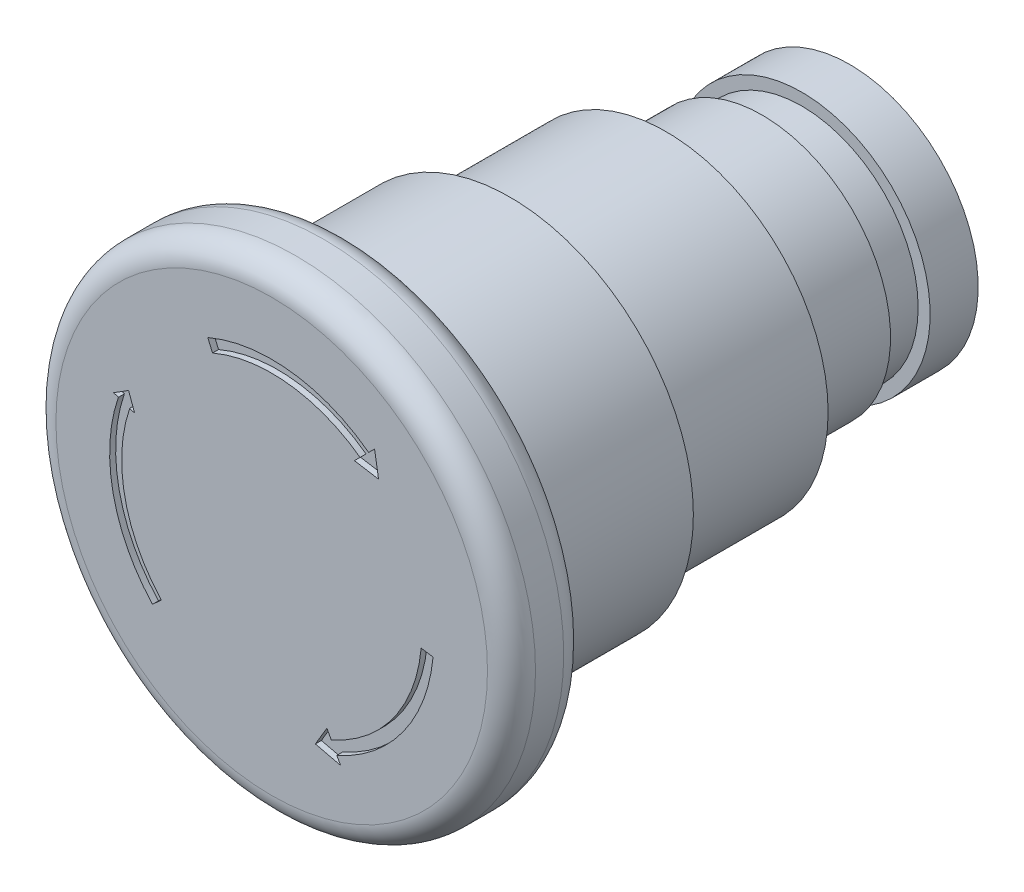
from build123d import *

# Parameters (mm, degrees)
SKETCH1_R           = 19.975
BOSS_EXTRUDE1_DEPTH = 6.35
SKETCH2_R           = 15.275
BOSS_EXTRUDE2_DEPTH = 13.5
SKETCH3_R           = 13.5
BOSS_EXTRUDE3_DEPTH = 13
SKETCH4_R           = 10.7
BOSS_EXTRUDE4_DEPTH = 15.3
FILLET1_R           = 2
SKETCH6_W           = 3.3
SKETCH6_H           = 1
CUT_EXTRUDE1_DEPTH  = 0.5


with BuildPart() as part:
    # Sketch1 → Boss-Extrude1 (new body)
    with BuildSketch(Plane.XY):
        Circle(SKETCH1_R)
    extrude(amount=BOSS_EXTRUDE1_DEPTH)

    # Sketch2 → Boss-Extrude2 (add)
    with BuildSketch(Plane(origin=(0, 0, 0), x_dir=(-1, 0, 0), z_dir=(0, 0, -1))):
        Circle(SKETCH2_R)
    extrude(amount=BOSS_EXTRUDE2_DEPTH)

    # Sketch3 → Boss-Extrude3 (add)
    with BuildSketch(Plane(origin=(0, 0, -13.5), x_dir=(-1, 0, 0), z_dir=(0, 0, -1))):
        Circle(SKETCH3_R)
    extrude(amount=BOSS_EXTRUDE3_DEPTH)

    # Sketch4 → Boss-Extrude4 (add)
    with BuildSketch(Plane(origin=(0, 0, -26.5), x_dir=(-1, 0, 0), z_dir=(0, 0, -1))):
        Circle(SKETCH4_R)
    extrude(amount=BOSS_EXTRUDE4_DEPTH)

    # Fillet1
    fillet1_edges = [part.edges().sort_by_distance(p)[0] for p in [
        (-19.975, 0, 0),
        (-19.975, 0, 6.35),
        (15.275, 0, 0),
    ]]
    fillet(fillet1_edges, radius=FILLET1_R)

    # Sketch6 → Cut-Revolve1 (revolve, cut)
    with BuildSketch(Plane(origin=(0, 0, 0), x_dir=(0, 0, -1), z_dir=(1, 0, 0))):
        with Locations((36.15, 10.2)):
            Rectangle(SKETCH6_W, SKETCH6_H)
    revolve(axis=Axis((0, 0, -41.8), (0, 0, 1)), mode=Mode.SUBTRACT)

    # Sketch7 → Cut-Extrude1 (cut)
    with BuildSketch(Plane.XY.offset(6.35)):
        with BuildLine():
            Line((7.361700557, 10.102245538), (6.889821654, 9.630366634))
            Line((6.889821654, 9.630366634), (8.901984725, 9.29752763))
            Line((8.901984725, 9.29752763), (8.569145721, 11.309690701))
            Line((8.569145721, 11.309690701), (8.076809244, 10.817354225))
            ThreePointArc((8.076809244, 10.817354225), (1.588975226, 13.406161186), (-5.32427617, 12.405727841))
            Line((-5.32427617, 12.405727841), (-4.929885342, 11.486785038))
            ThreePointArc((-4.929885342, 11.486785038), (1.399167151, 12.421446425), (7.361700557, 10.102245538))
        make_face()
        with BuildLine():
            Line((5.42803449, -12.360681275), (5.733177226, -12.931740939))
            Line((5.733177226, -12.931740939), (3.638222105, -12.432470591))
            Line((3.638222105, -12.432470591), (4.600377681, -10.81176215))
            Line((4.600377681, -10.81176215), (4.955240265, -11.475870072))
            ThreePointArc((4.955240265, -11.475870072), (10.129078424, -7.324736874), (12.450535159, -1.110933952))
            Line((12.450535159, -1.110933952), (13.440903952, -1.261784828))
            ThreePointArc((13.440903952, -1.261784828), (10.945573766, -7.90217786), (5.42803449, -12.360681275))
        make_face()
        with BuildLine():
            ThreePointArc((-11.826988096, 4.046276383), (-12.232403131, -2.572608334), (-9.195209209, -8.467474689))
            Line((-9.195209209, -8.467474689), (-9.930825945, -9.144872664))
            ThreePointArc((-9.930825945, -9.144872664), (-13.210995381, -2.778417001), (-12.773147144, 4.369978494))
            Line((-12.773147144, 4.369978494), (-13.168055986, 4.505085616))
            Line((-13.168055986, 4.505085616), (-11.922567938, 5.286415043))
            Line((-11.922567938, 5.286415043), (-11.416693258, 3.905905369))
            Line((-11.416693258, 3.905905369), (-11.826988096, 4.046276383))
        make_face()
    extrude(amount=-CUT_EXTRUDE1_DEPTH, mode=Mode.SUBTRACT)


solid = part.part
